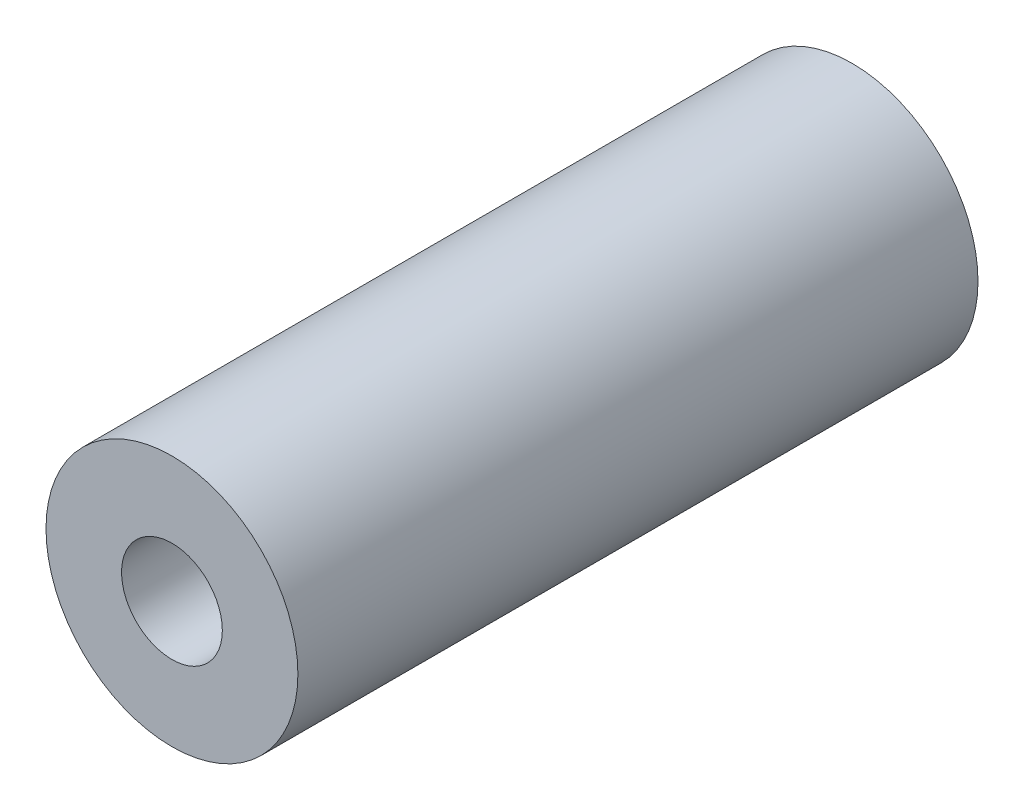
from build123d import *

# Parameters (mm, degrees)
SKETCH_1_R          = 10
EXTRUDE_1_DEPTH     = 54
SKETCH_2_R          = 4
CUT_EXTRUDE_1_DEPTH = 55


with BuildPart() as part:
    # 草图1 → 凸台-拉伸1 (new body)
    with BuildSketch(Plane.XY):
        Circle(SKETCH_1_R)
    extrude(amount=EXTRUDE_1_DEPTH)

    # 草图2 → 切除-拉伸1 (cut, through all)
    with BuildSketch(Plane.XY.offset(54)):
        Circle(SKETCH_2_R)
    extrude(amount=-CUT_EXTRUDE_1_DEPTH, mode=Mode.SUBTRACT)


solid = part.part
